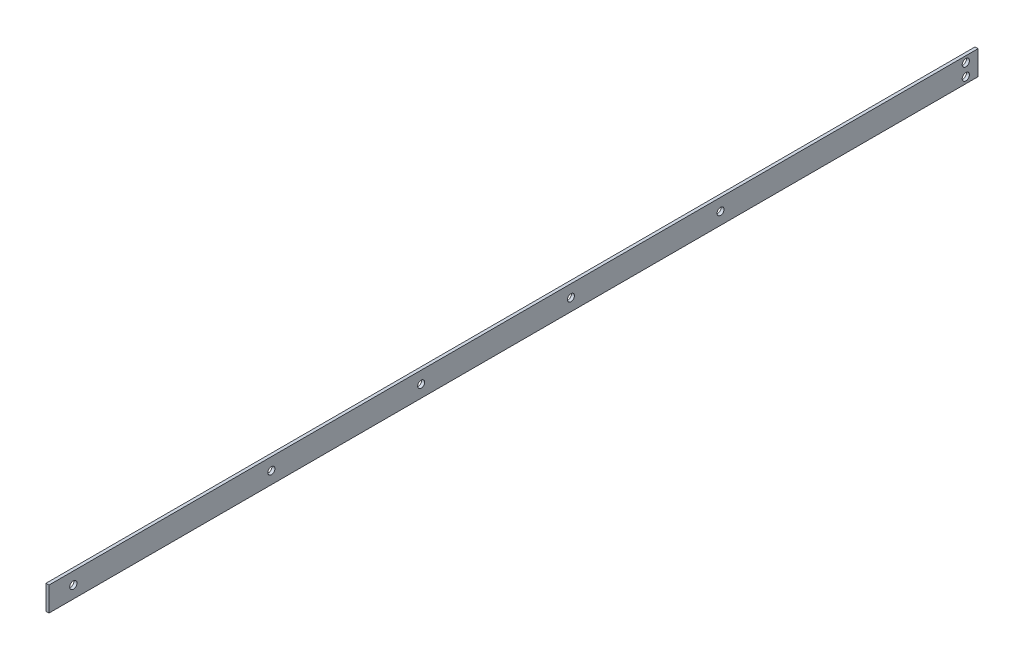
from build123d import *

# Parameters (mm, degrees)
SKETCH1_W             = 1.5875
SKETCH1_H             = 12.7
BOSS_EXTRUDE1_DEPTH   = 485.14
F_6_CLEARANCE_HOLE2_D = 3.7973
F_6_CLEARANCE_HOLE1_D = 3.7973
F_6_CLEARANCE_HOLE3_D = 3.6576


with BuildPart() as part:
    # Sketch1 → Boss-Extrude1 (new body)
    with BuildSketch(Plane.XY):
        with Locations((0.79375, 6.35)):
            Rectangle(SKETCH1_W, SKETCH1_H)
    extrude(amount=BOSS_EXTRUDE1_DEPTH)

    # #6 Clearance Hole2 (through all)
    with Locations(Plane(origin=(1.5875, 0, 0), x_dir=(0, 0, -1), z_dir=(1, 0, 0))):
        with Locations((-6.35, 9.525), (-6.35, 3.175)):
            Hole(F_6_CLEARANCE_HOLE2_D / 2)

    # #6 Clearance Hole1 (through all)
    with Locations(Plane(origin=(1.5875, 0, 0), x_dir=(0, 0, -1), z_dir=(1, 0, 0))):
        with Locations((-472.44, 6.35)):
            Hole(F_6_CLEARANCE_HOLE1_D / 2)

    # #6 Clearance Hole3 (through all)
    with Locations(Plane(origin=(1.5875, -24.631267391, -47.650434272), x_dir=(0, 0, -1), z_dir=(1, 0, 0))):
        with Locations((-416.683873726, 30.981267391), (-338.451873726, 30.981267391), (-260.219873726, 30.981267391), (-182.081072585, 30.981267391)):
            Hole(F_6_CLEARANCE_HOLE3_D / 2)


solid = part.part
